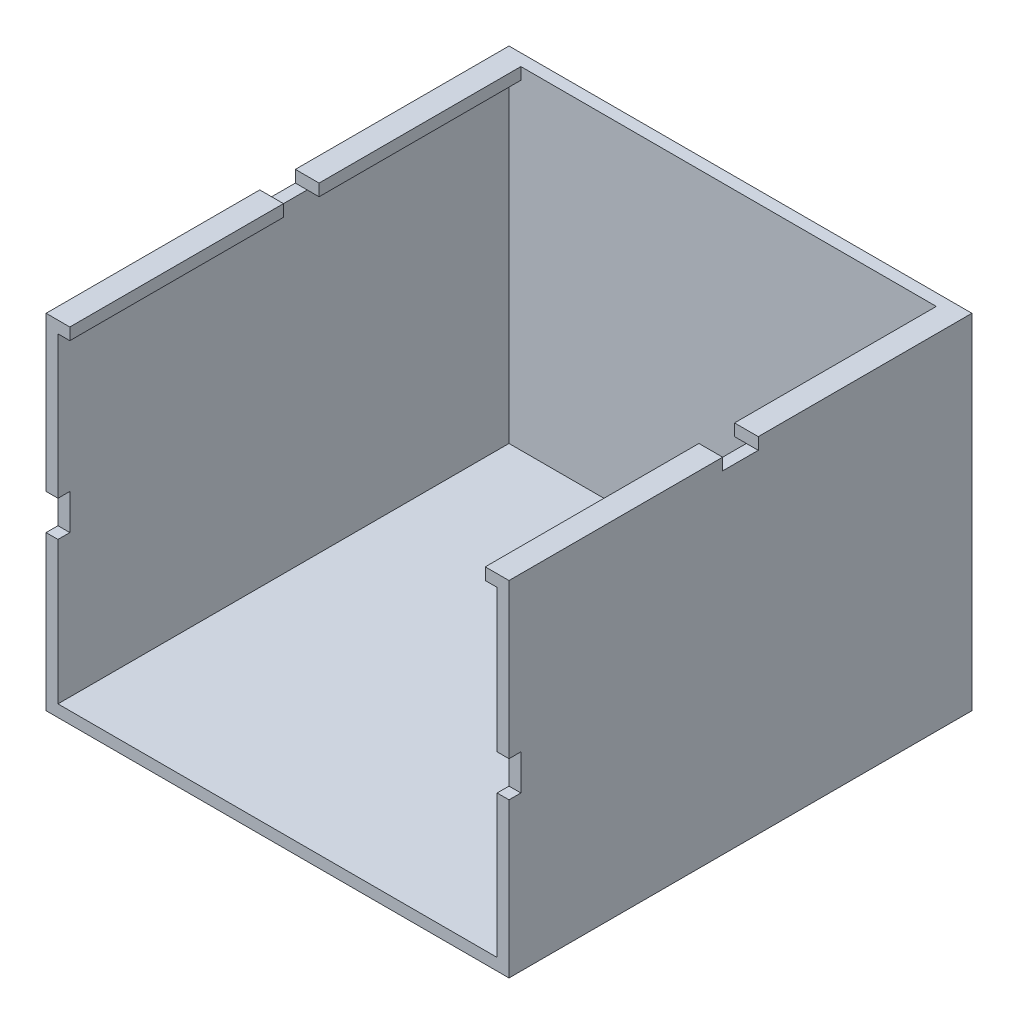
from build123d import *

# Parameters (mm, degrees)
SKETCH1_W           = 39
SKETCH1_H           = 39
BOSS_EXTRUDE1_DEPTH = 29
SKETCH3_W           = 37
SKETCH3_H           = 27
CUT_EXTRUDE1_DEPTH  = 38
SKETCH4_W           = 35
SKETCH4_H           = 38.588060521
CUT_EXTRUDE2_DEPTH  = 10
CUT_EXTRUDE3_START  = 27
SKETCH5_W           = 40
SKETCH5_H           = 3
CUT_EXTRUDE3_DEPTH  = 4
CUT_EXTRUDE5_START  = 38
SKETCH6_W           = 41.777462506
SKETCH6_H           = 3
CUT_EXTRUDE5_DEPTH  = 1


with BuildPart() as part:
    # Sketch1 → Boss-Extrude1 (new body)
    with BuildSketch(Plane(origin=(0, 0, 0), x_dir=(1, 0, 0), z_dir=(0, 1, 0))):
        with Locations((-4.072718242, -0.197565543)):
            Rectangle(SKETCH1_W, SKETCH1_H)
    extrude(amount=BOSS_EXTRUDE1_DEPTH)

    # Sketch3 → Cut-Extrude1 (cut)
    with BuildSketch(Plane.XY.offset(19.697565543)):
        with Locations((-4.072718242, 14.5)):
            Rectangle(SKETCH3_W, SKETCH3_H)
    extrude(amount=-CUT_EXTRUDE1_DEPTH, mode=Mode.SUBTRACT)

    # Sketch4 → Cut-Extrude2 (cut)
    with BuildSketch(Plane(origin=(0, 29, 0), x_dir=(1, 0, 0), z_dir=(0, 1, 0))):
        with Locations((-4.072718242, -0.991595804)):
            Rectangle(SKETCH4_W, SKETCH4_H)
    extrude(amount=-CUT_EXTRUDE2_DEPTH, mode=Mode.SUBTRACT)

    # Sketch5 → Cut-Extrude3 (cut)
    with BuildSketch(Plane(origin=(0, 1, 0), x_dir=(1, 0, 0), z_dir=(0, 1, 0)).offset(CUT_EXTRUDE3_START)):
        with Locations((-4.288618926, -0.197565543)):
            Rectangle(SKETCH5_W, SKETCH5_H)
    extrude(amount=CUT_EXTRUDE3_DEPTH, mode=Mode.SUBTRACT)

    # Sketch6 → Cut-Extrude5 (cut)
    with BuildSketch(Plane.XY.offset(-18.302434457).offset(CUT_EXTRUDE5_START)):
        with Locations((-4.415990597, 14.5)):
            Rectangle(SKETCH6_W, SKETCH6_H)
    extrude(amount=-CUT_EXTRUDE5_DEPTH, mode=Mode.SUBTRACT)


solid = part.part
